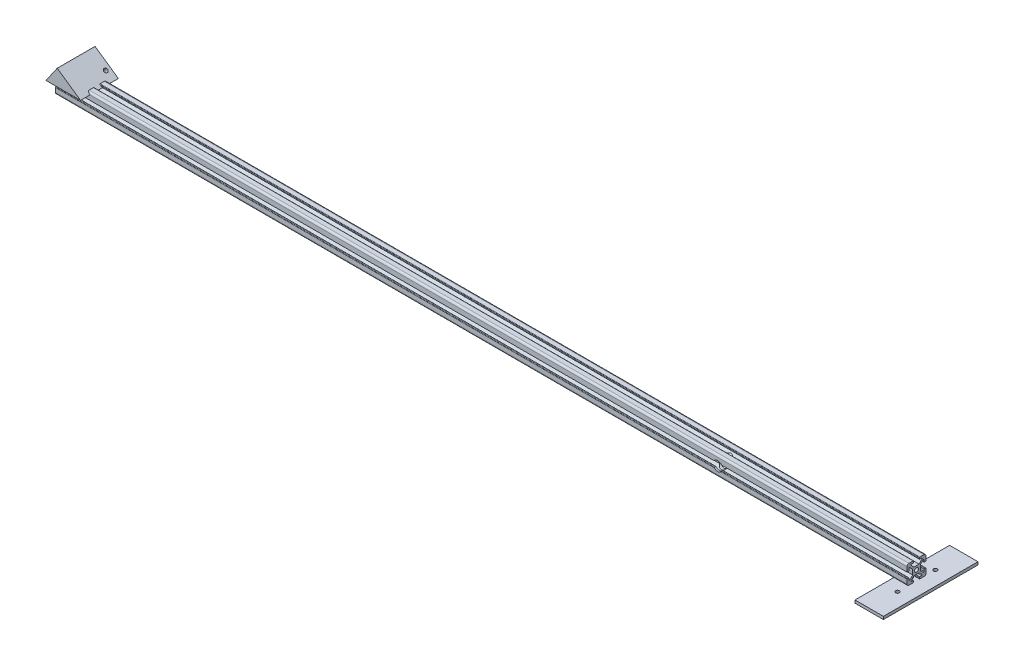
from build123d import *

# Parameters (mm, degrees)
SKETCH2_R                       = 2
ALUMINIUM_PROFILE_20_20_1_DEPTH = 1000
SKETCH3_R                       = 5
CUT_EXTRUDE1_DEPTH              = 50
SKETCH4_W                       = 30
SKETCH4_H                       = 100
BOSS_EXTRUDE1_DEPTH             = 3
SKETCH5_R                       = 2
CUT_EXTRUDE2_DEPTH              = 10
SKETCH10_W                      = 53.187273646
SKETCH10_H                      = 37.053500666
CUT_EXTRUDE5_DEPTH              = 100
BOSS_EXTRUDE2_DEPTH             = 10
BOSS_EXTRUDE2_DEPTH_BACK        = 30
SKETCH14_R                      = 2
CUT_EXTRUDE8_DEPTH              = 40
SKETCH13_R                      = 2
CUT_EXTRUDE9_DEPTH              = 838.568289699


with BuildPart() as part:
    # Sketch2 → Aluminium profile 20×20(1) (new body)
    with BuildSketch(Plane(origin=(0, 0, 0), x_dir=(0, -1, 0), z_dir=(-1, 0, 0))):
        with BuildLine():
            Line((-2.666639653, -4), (2.666639653, -4))
            Line((2.666639653, -4), (5.776647091, -7.148635412))
            ThreePointArc((5.776647091, -7.148635412), (5.882265465, -7.692766317), (5.420918365, -8))
            Line((5.420918365, -8), (3.498570355, -8))
            ThreePointArc((3.498570355, -8), (3.145016964, -8.146446609), (2.998570355, -8.5))
            Line((2.998570355, -8.5), (2.998570355, -9.5))
            ThreePointArc((2.998570355, -9.5), (3.145016964, -9.853553391), (3.498570355, -10))
            Line((3.498570355, -10), (7.998570355, -10))
            ThreePointArc((7.998570355, -10), (9.412783917, -9.414213562), (9.998570355, -8))
            Line((9.998570355, -8), (9.998570355, -3.5))
            ThreePointArc((9.998570355, -3.5), (9.852123746, -3.146446609), (9.498570355, -3))
            Line((9.498570355, -3), (8.498570355, -3))
            ThreePointArc((8.498570355, -3), (8.145016964, -3.146446609), (7.998570355, -3.5))
            Line((7.998570355, -3.5), (7.998570355, -5.412091861))
            ThreePointArc((7.998570355, -5.412091861), (7.691000546, -5.873579263), (7.146687869, -5.767308297))
            Line((7.146687869, -5.767308297), (4, -2.650154242))
            Line((4, -2.650154242), (4, 2.650154242))
            Line((4, 2.650154242), (7.146687869, 5.767308297))
            ThreePointArc((7.146687869, 5.767308297), (7.691000546, 5.873579263), (7.998570355, 5.412091861))
            Line((7.998570355, 5.412091861), (7.998570355, 3.5))
            ThreePointArc((7.998570355, 3.5), (8.145016964, 3.146446609), (8.498570355, 3))
            Line((8.498570355, 3), (9.498570355, 3))
            ThreePointArc((9.498570355, 3), (9.852123746, 3.146446609), (9.998570355, 3.5))
            Line((9.998570355, 3.5), (9.998570355, 8))
            ThreePointArc((9.998570355, 8), (9.412783917, 9.414213562), (7.998570355, 10))
            Line((7.998570355, 10), (3.498570355, 10))
            ThreePointArc((3.498570355, 10), (3.145016964, 9.853553391), (2.998570355, 9.5))
            Line((2.998570355, 9.5), (2.998570355, 8.5))
            ThreePointArc((2.998570355, 8.5), (3.145016964, 8.146446609), (3.498570355, 8))
            Line((3.498570355, 8), (5.420918365, 8))
            ThreePointArc((5.420918365, 8), (5.882265465, 7.692766317), (5.776647091, 7.148635412))
            Line((5.776647091, 7.148635412), (2.666639653, 4))
            Line((2.666639653, 4), (-2.666639653, 4))
            Line((-2.666639653, 4), (-5.776647091, 7.148635412))
            ThreePointArc((-5.776647091, 7.148635412), (-5.882265465, 7.692766317), (-5.420918365, 8))
            Line((-5.420918365, 8), (-2.998570355, 8))
            Line((-2.998570355, 8), (-2.998570355, 10))
            Line((-2.998570355, 10), (-7.998570355, 10))
            ThreePointArc((-7.998570355, 10), (-9.412783917, 9.414213562), (-9.998570355, 8))
            Line((-9.998570355, 8), (-9.998570355, 3.5))
            ThreePointArc((-9.998570355, 3.5), (-9.852123746, 3.146446609), (-9.498570355, 3))
            Line((-9.498570355, 3), (-8.498570355, 3))
            ThreePointArc((-8.498570355, 3), (-8.145016964, 3.146446609), (-7.998570355, 3.5))
            Line((-7.998570355, 3.5), (-7.998570355, 5.412091861))
            ThreePointArc((-7.998570355, 5.412091861), (-7.691000546, 5.873579263), (-7.146687869, 5.767308297))
            Line((-7.146687869, 5.767308297), (-4, 2.650154242))
            Line((-4, 2.650154242), (-4, -2.650154242))
            Line((-4, -2.650154242), (-7.146687869, -5.767308297))
            ThreePointArc((-7.146687869, -5.767308297), (-7.691000546, -5.873579263), (-7.998570355, -5.412091861))
            Line((-7.998570355, -5.412091861), (-7.998570355, -3.5))
            ThreePointArc((-7.998570355, -3.5), (-8.145016964, -3.146446609), (-8.498570355, -3))
            Line((-8.498570355, -3), (-9.498570355, -3))
            ThreePointArc((-9.498570355, -3), (-9.852123746, -3.146446609), (-9.998570355, -3.5))
            Line((-9.998570355, -3.5), (-9.998570355, -8))
            ThreePointArc((-9.998570355, -8), (-9.412783917, -9.414213562), (-7.998570355, -10))
            Line((-7.998570355, -10), (-3.498570355, -10))
            ThreePointArc((-3.498570355, -10), (-3.145016964, -9.853553391), (-2.998570355, -9.5))
            Line((-2.998570355, -9.5), (-2.998570355, -8.5))
            ThreePointArc((-2.998570355, -8.5), (-3.145016964, -8.146446609), (-3.498570355, -8))
            Line((-3.498570355, -8), (-5.420918365, -8))
            ThreePointArc((-5.420918365, -8), (-5.882265465, -7.692766317), (-5.776647091, -7.148635412))
            Line((-5.776647091, -7.148635412), (-2.666639653, -4))
        make_face()
        Circle(SKETCH2_R, mode=Mode.SUBTRACT)
    extrude(amount=ALUMINIUM_PROFILE_20_20_1_DEPTH)

    # Sketch3 → Cut-Extrude1 (cut)
    with BuildSketch(Plane.XY.offset(10)):
        with Locations(Location((-300, 0, 0), (0, 0, 327.769413306))):
            Circle(SKETCH3_R)
    extrude(amount=-CUT_EXTRUDE1_DEPTH, mode=Mode.SUBTRACT)

    # Sketch10 → Cut-Extrude5 (cut)
    with BuildSketch(Plane(origin=(0, 0, 0), x_dir=(0, 0, -1), z_dir=(1, 0, 0))):
        Rectangle(SKETCH10_W, SKETCH10_H)
    extrude(amount=-CUT_EXTRUDE5_DEPTH, mode=Mode.SUBTRACT)


with BuildPart() as body_2:
    # Sketch4 → Boss-Extrude1 (new body)
    with BuildSketch(Plane.XZ.offset(9.998570355)):
        with Locations((-100, 0)):
            Rectangle(SKETCH4_W, SKETCH4_H)
    extrude(amount=BOSS_EXTRUDE1_DEPTH)

    # Sketch5 → Cut-Extrude2 (cut)
    with BuildSketch(Plane.XZ.offset(12.998570355)):
        with Locations((-100, 20)):
            Circle(SKETCH5_R)
        with Locations((-100, -20)):
            Circle(SKETCH5_R)
    extrude(amount=-CUT_EXTRUDE2_DEPTH, mode=Mode.SUBTRACT)


with BuildPart() as body_3:
    # Sketch11 → Boss-Extrude2 (new, two sides)
    with BuildSketch(Plane.XY.offset(10)) as boss_extrude2_sk:
        Polygon((-1000, 7.998570355), (-988.144845815, 25.094132061), (-963.492426665, 7.998570355), align=None)
    extrude(amount=BOSS_EXTRUDE2_DEPTH)
    extrude(boss_extrude2_sk.sketch, amount=-BOSS_EXTRUDE2_DEPTH_BACK)

    # Sketch13 → Cut-Extrude9 (cut, through all)
    with BuildSketch(Plane(origin=(-309.130686871, -445.777646608, 0), x_dir=(0.8217473049997495, -0.5698520568758605, 0), z_dir=(0.5698520568758605, 0.8217473049997495, 0))):
        with Locations(Location((-806.415155121, 15, 0), (0, 0, 180))):
            Circle(SKETCH13_R)
    extrude(amount=-CUT_EXTRUDE9_DEPTH, mode=Mode.SUBTRACT)


with BuildPart() as cut_extrude8_tool:
    # Sketch14 → Cut-Extrude8 (new body)
    with BuildSketch(Plane(origin=(0, 4, 0), x_dir=(1, 0, 0), z_dir=(0, 1, 0))):
        with Locations((-105.996133033, 0)):
            Circle(SKETCH14_R)
    extrude(amount=-CUT_EXTRUDE8_DEPTH)


with BuildPart() as part_1:
    add(part.part)

    # Cut-Extrude8: cut by cut_extrude8_tool
    add(cut_extrude8_tool.part, mode=Mode.SUBTRACT)


with BuildPart() as body_2_1:
    add(body_2.part)

    # Cut-Extrude8: cut by cut_extrude8_tool
    add(cut_extrude8_tool.part, mode=Mode.SUBTRACT)


solid = Compound([body_3.part, part_1.part, body_2_1.part])
